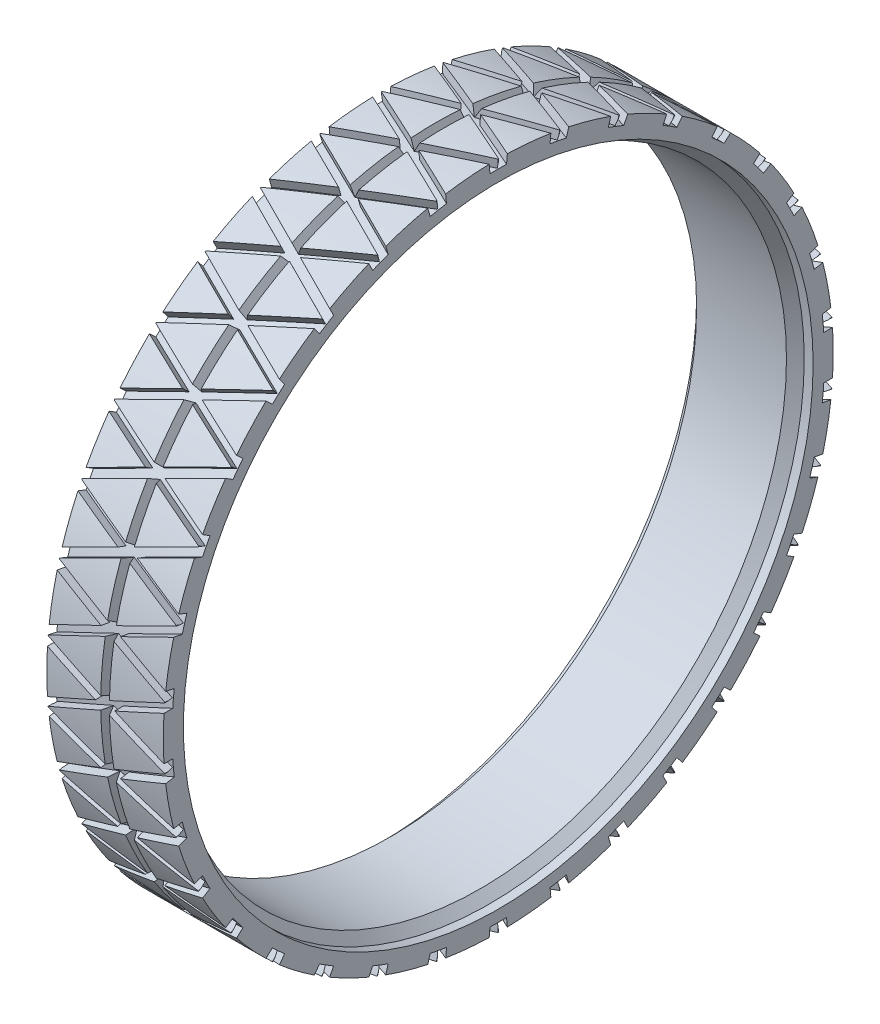
from build123d import *
from build123d.topology import SkipClean

# Parameters (mm, degrees)
CUT_EXTRUDE1_REACH      = 261.709
CUT_EXTRUDE1_END_RADIUS = 112
CIRPATTERN1_COUNT       = 34


with BuildPart() as part:
    # Sketch1 → Revolve1 (revolve)
    with BuildSketch(Plane.XY, mode=Mode.PRIVATE) as revolve1_sk:
        Polygon((-20, 115), (20, 115), (20, 108.1), (16.95, 108.1), (13.9, 105.05), (-16.95, 105.05), (-16.95, 108.1), (-20, 108.1), align=None)
    revolve(revolve1_sk.sketch.rotate(Axis((22, 0, 0), (-1, 0, 0)), 90), axis=Axis((22, 0, 0), (-1, 0, 0)))

    # Cut-Extrude1: up to this cylinder (the profile starts outside it)
    cut_extrude1_end = Plane(origin=(0, 0, 0), z_dir=(-1, 0, 0)) * Cylinder(CUT_EXTRUDE1_END_RADIUS, 748.418, mode=Mode.PRIVATE)
    # Sketch3 → Cut-Extrude1 (cut, up to the surface)
    with BuildSketch(Plane.XY.offset(117), mode=Mode.PRIVATE) as cut_extrude1_sk1:
        Polygon((-20, 7.5), (-3.333333333, 0), (-20, -7.5), (-20, -10.5), (0, -1.5), (20, -10.5), (20, -7.5), (3.333333333, 0), (20, 7.5), (20, 10.5), (0, 1.5), (-20, 10.5), align=None)
    cut_extrude1_tool1 = extrude(cut_extrude1_sk1.sketch, amount=-CUT_EXTRUDE1_REACH, mode=Mode.PRIVATE) - cut_extrude1_end
    cut_extrude1 = cut_extrude1_tool1.solids().sort_by_distance((0, 0, 117))[0]
    add(cut_extrude1, mode=Mode.SUBTRACT)

    # CirPattern1: Cut-Extrude1 ×34 about axis
    with SkipClean():  # the faces are left unmerged after this step: merging them gives an invalid solid
        cirpattern1_axis = Axis((0, 0, 0), (1, 0, 0))
        for i in range(1, CIRPATTERN1_COUNT):
            add(cut_extrude1.rotate(cirpattern1_axis, i * 360 / CIRPATTERN1_COUNT), mode=Mode.SUBTRACT)

    # Sketch4 → Cut-Revolve1 (revolve, cut)
    with SkipClean():  # the faces are left unmerged after this step: merging them gives an invalid solid
        with BuildSketch(Plane.XY, mode=Mode.PRIVATE) as cut_revolve1_sk:
            Polygon((-1.5, 115), (1.5, 115), (0, 112), align=None)
        revolve(cut_revolve1_sk.sketch.rotate(Axis((22, 0, 0), (-1, 0, 0)), 270), axis=Axis((22, 0, 0), (-1, 0, 0)), mode=Mode.SUBTRACT)


solid = part.part
